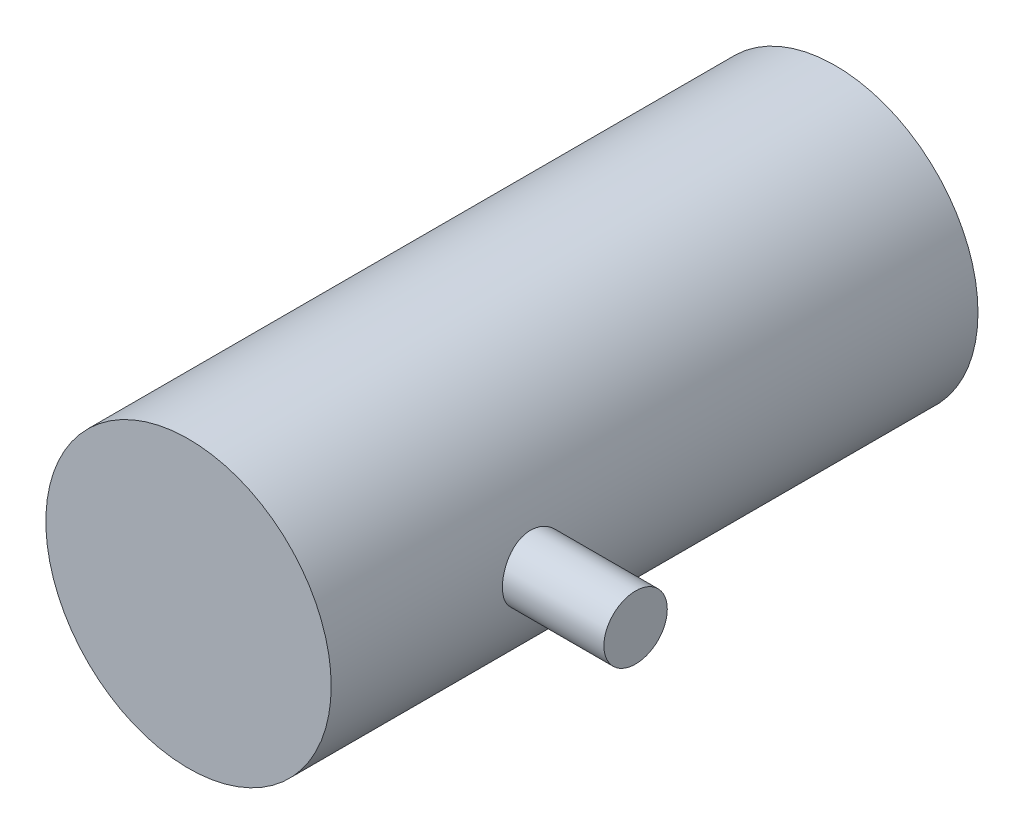
from build123d import *

# Parameters (mm, degrees)
CROQUIS1_R              = 225
SALIENTE_EXTRUIR1_DEPTH = 1020
CROQUIS2_R              = 50
SALIENTE_EXTRUIR2_DEPTH = 385


with BuildPart() as part:
    # Croquis1 → Saliente-Extruir1 (new body)
    with BuildSketch(Plane.XY):
        Circle(CROQUIS1_R)
    extrude(amount=SALIENTE_EXTRUIR1_DEPTH)

    # Croquis2 → Saliente-Extruir2 (add)
    with BuildSketch(Plane(origin=(0, 0, 0), x_dir=(0, 0, -1), z_dir=(1, 0, 0))):
        with Locations((-700, 0)):
            Circle(CROQUIS2_R)
    extrude(amount=SALIENTE_EXTRUIR2_DEPTH)


solid = part.part
